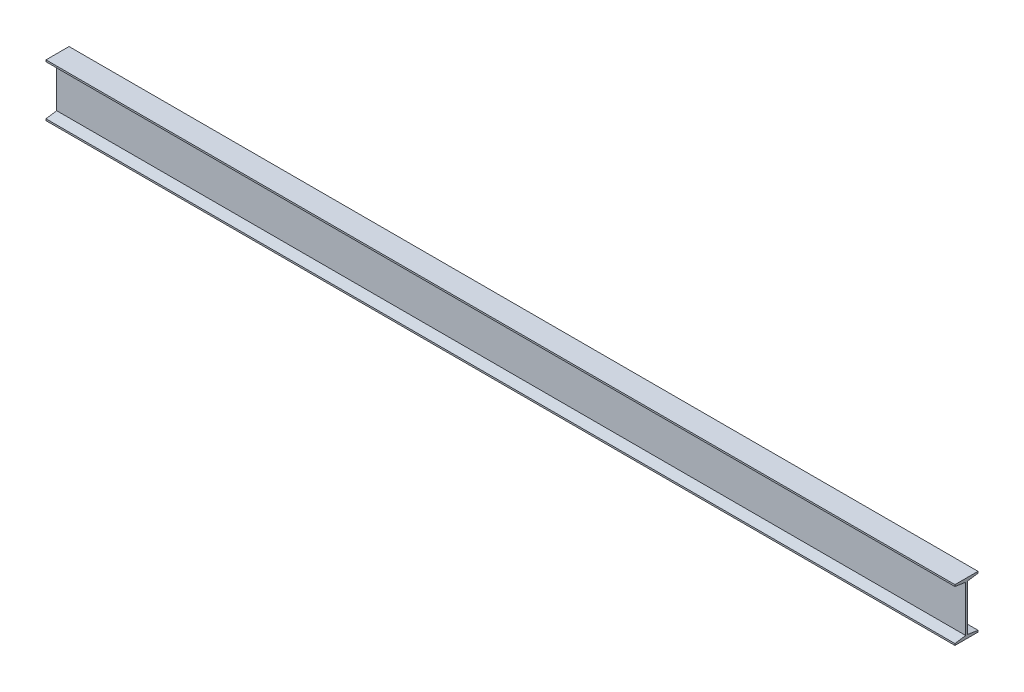
from build123d import *

# Parameters (mm, degrees)
BOSS_EXTRUDE1_DEPTH = 3505.2


with BuildPart() as part:
    # Sketch1 → Boss-Extrude1 (new body)
    with BuildSketch(Plane(origin=(0, 0, 0), x_dir=(0, 0, -1), z_dir=(1, 0, 0))):
        Polygon((0, 0), (0, 6.35), (41.275, 12.7), (41.275, 190.5), (0, 196.85), (0, 203.2), (88.9, 203.2), (88.9, 196.85), (47.625, 190.5), (47.625, 12.7), (88.9, 6.35), (88.9, 0), align=None)
    extrude(amount=BOSS_EXTRUDE1_DEPTH)


solid = part.part
